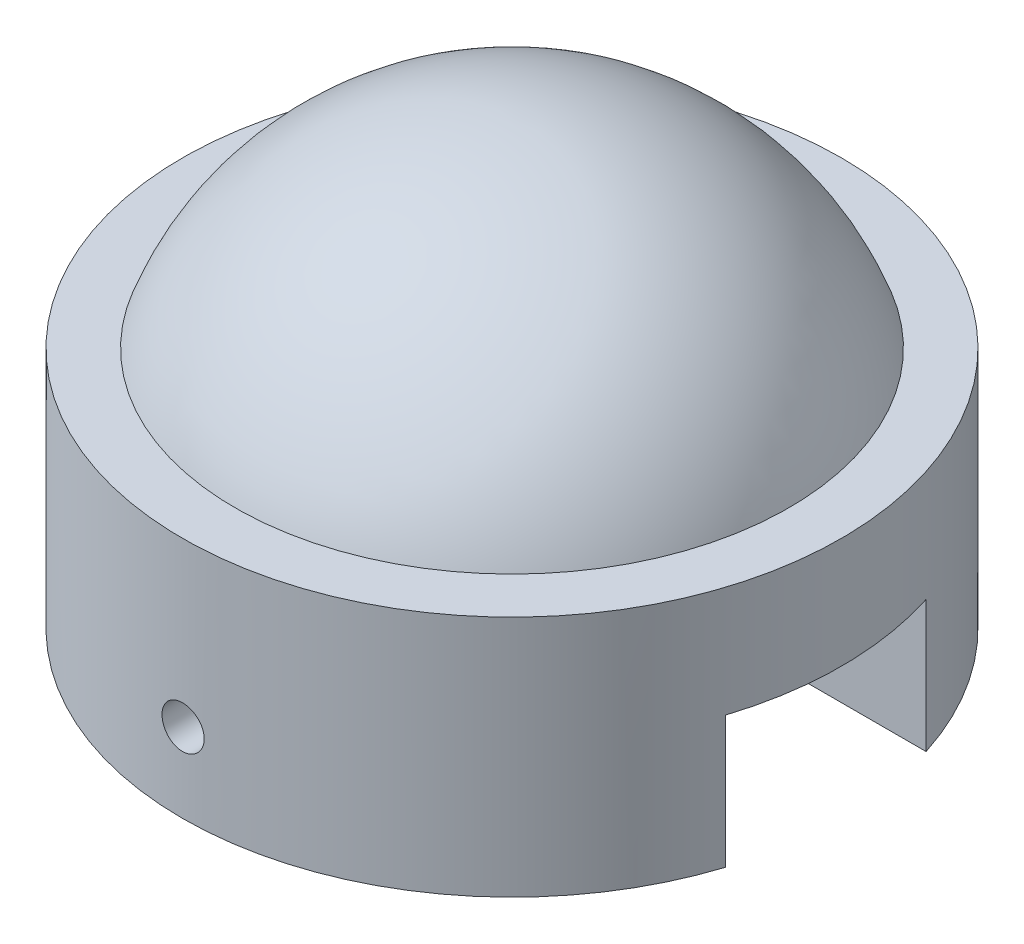
from build123d import *

# Parameters (mm, degrees)
CUT_EXTRUDE1_DEPTH      = 10
CUT_EXTRUDE1_DEPTH_BACK = 13.124974227
SKETCH2_W               = 3.8
SKETCH2_H               = 2.5
CUT_EXTRUDE2_DEPTH      = 13.124974227
CUT_EXTRUDE2_DEPTH_BACK = 13.124974227
SKETCH3_R               = 0.4


with BuildPart() as part:
    # Sketch1 → Revolve1 (revolve)
    with BuildSketch(Plane.XY):
        with BuildLine():
            Line((0, 8.3), (0, 5.6))
            ThreePointArc((0, 5.6), (-2.071834936, 5.23939732), (-3.9, 4.2))
            Line((-3.9, 4.2), (-3.9, 0))
            Line((-3.9, 0), (-6.25, 0))
            Line((-6.25, 0), (-6.25, 4.6))
            Line((-6.25, 4.6), (-5.25, 4.6))
            ThreePointArc((-5.25, 4.6), (-3.211405456, 7.282061795), (0, 8.3))
        make_face()
    revolve(axis=Axis((0, 0, 0), (0, 1, 0)))

    # Sketch2 → Cut-Extrude1 (cut, two sides: drawn at the far end of the back side and taken through both)
    with BuildSketch(Plane(origin=(0, 0, 0), x_dir=(0, 0, -1), z_dir=(1, 0, 0)).offset(-CUT_EXTRUDE1_DEPTH_BACK)):
        with Locations((0, 1.25)):
            Rectangle(SKETCH2_W, SKETCH2_H)
    extrude(amount=CUT_EXTRUDE1_DEPTH + CUT_EXTRUDE1_DEPTH_BACK, mode=Mode.SUBTRACT)

    # Sketch3 → Cut-Extrude2 (cut, two sides: drawn at the far end of the back side and taken through both)
    with BuildSketch(Plane.XY.offset(-CUT_EXTRUDE2_DEPTH_BACK)):
        with Locations((0, 1.5)):
            Circle(SKETCH3_R)
    extrude(amount=CUT_EXTRUDE2_DEPTH + CUT_EXTRUDE2_DEPTH_BACK, mode=Mode.SUBTRACT)


solid = part.part
